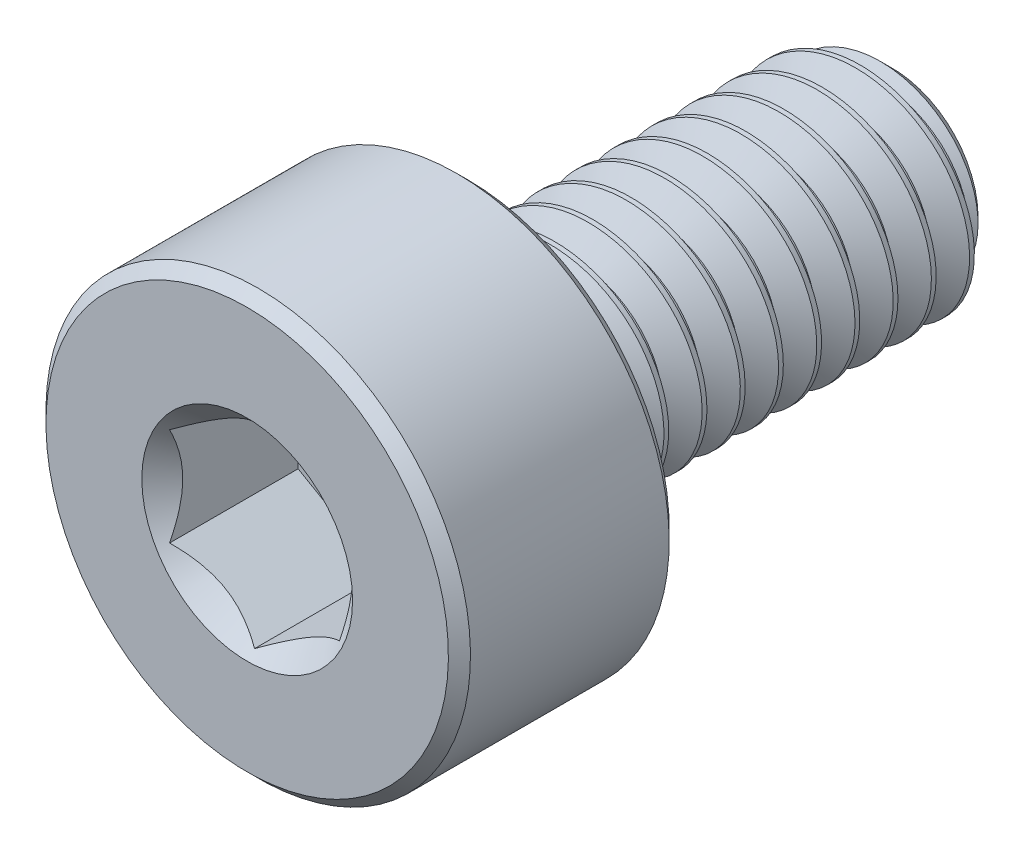
from build123d import *

# Parameters (mm, degrees)
CUT_EXTRUDE1_DEPTH     = 1.6
SPLIT1_SURFACE_1_BACK  = 11.381
SPLIT1_SURFACE_1_DEPTH = 22.762
SPLIT1_SURFACE_2_BACK  = 11.381
SPLIT1_SURFACE_2_DEPTH = 22.762
CUT_SWEEP1_PITCH       = 0.4500000000000005
CUT_SWEEP1_HEIGHT      = 5.45000000000001
CUT_SWEEP1_RADIUS      = 1.3
CUT_SWEEP1_START_ANGLE = 89.99999999999977


with BuildPart() as part:
    # Sketch2 → Revolve1 (revolve)
    with BuildSketch(Plane(origin=(0, 0, 0), x_dir=(0, 0, -1), z_dir=(1, 0, 0))):
        with BuildLine():
            Line((-3.799999999999998, 0), (-3.7999999999999994, 2.3699999999999997))
            Line((-3.7999999999999994, 2.3699999999999997), (-3.6699999999999995, 2.5))
            Line((-3.6699999999999995, 2.5), (-1.3299999999999996, 2.5))
            Line((-1.3299999999999996, 2.5), (-1.1999999999999997, 2.3699999999999997))
            Line((-1.1999999999999997, 2.3699999999999997), (-1.1999999999999997, 1.430000000000001))
            ThreePointArc((-1.1999999999999997, 1.430000000000001), (-1.1619238815542512, 1.3380761184457506), (-1.0700000000000007, 1.300000000000001))
            Line((-1.0700000000000007, 1.300000000000001), (3.507716426222749, 1.3))
            Line((3.507716426222749, 1.3), (3.7999999999999994, 1.0077164262227518))
            Line((3.7999999999999994, 1.0077164262227518), (3.799999999999998, 0))
            Line((3.799999999999998, 0), (-3.799999999999998, 0))
        make_face()
    revolve(axis=Axis((0, 0, -3.799999999999998), (0, 0, 1)))

    # Sketch3 → Cut-Extrude1 (cut)
    with BuildSketch(Plane.XY.offset(3.7999999999999985)):
        Polygon((1, -0.5773502691896257), (1, 0.5773502691896258), (-3.1e-16, 1.1547005383792517), (-1, 0.5773502691896255), (-1, -0.5773502691896258), (4.4e-16, -1.1547005383792517), align=None)
    extrude(amount=-CUT_EXTRUDE1_DEPTH, mode=Mode.SUBTRACT)

    # Cut-Extrude2 cone 1 section (through the dimple's axis) → Cut-Extrude2 (revolve, cut)
    with BuildSketch(Plane(origin=(0, 0, 3.8), x_dir=(0, -1, 0), z_dir=(1, 0, 0))):
        Polygon((0, 0), (1.241303079, 0), (0, 1.241303079), align=None)
    revolve(axis=Axis((0, 0, 3.8), (0, 0, -1)), mode=Mode.SUBTRACT)


with BuildPart() as body_2:
    # Split1: the piece behind the surface
    add(part.part)
    # Split1 surface: a surface, the sketch's curves swept straight by 22.762 mm
    with BuildLine(Plane(origin=(0, 0, 0), x_dir=(0, 0, -1), z_dir=(1, 0, 0)).offset(-SPLIT1_SURFACE_1_BACK), mode=Mode.PRIVATE) as split1_surface_1_path:
        Line((-1.0700000000000007, -2.5000000000000004), (-1.0700000000000007, 2.5000000000000004))
    split1_surface_1 = Shell.extrude(split1_surface_1_path.wire(), (1 * SPLIT1_SURFACE_1_DEPTH, 0 * SPLIT1_SURFACE_1_DEPTH, 0 * SPLIT1_SURFACE_1_DEPTH))
    split(bisect_by=split1_surface_1, keep=Keep.BOTTOM)

    # Cut-Sweep1: sweep along a helix
    with BuildLine() as cut_sweep1_path:
        add(Helix(CUT_SWEEP1_PITCH, CUT_SWEEP1_HEIGHT, CUT_SWEEP1_RADIUS, center=(0, 0, -3.7999999999999985), direction=(0, 0, 1), mode=Mode.PRIVATE).rotate(Axis((0, 0, -3.7999999999999985), (0, 0, 1)), CUT_SWEEP1_START_ANGLE))
    # Sketch7 → Cut-Sweep1 (sweep, cut)
    with BuildSketch(Plane(origin=(0, 0, 0), x_dir=(0, 0, -1), z_dir=(1, 0, 0))):
        Polygon((3.78593750000002, 1.324356964481437), (4.207812499999981, 1.324356964481437), (4.0249999999999995, 1.0077164262227518), (3.9687499999999982, 1.0077164262227518), align=None)
    sweep(path=cut_sweep1_path.line, is_frenet=True, mode=Mode.SUBTRACT)


with BuildPart() as part_1:
    add(part.part)

    # Split1: split by a surface, the side it looks to stays
    # Split1 surface: a surface, the sketch's curves swept straight by 22.762 mm
    with BuildLine(Plane(origin=(0, 0, 0), x_dir=(0, 0, -1), z_dir=(1, 0, 0)).offset(-SPLIT1_SURFACE_2_BACK), mode=Mode.PRIVATE) as split1_surface_2_path:
        Line((-1.0700000000000007, -2.5000000000000004), (-1.0700000000000007, 2.5000000000000004))
    split1_surface_2 = Shell.extrude(split1_surface_2_path.wire(), (1 * SPLIT1_SURFACE_2_DEPTH, 0 * SPLIT1_SURFACE_2_DEPTH, 0 * SPLIT1_SURFACE_2_DEPTH))
    split(bisect_by=split1_surface_2, keep=Keep.TOP)

    add(body_2.part)  # Revolve2 merges body 2
    # Sketch8 → Revolve2 (revolve)
    with BuildSketch(Plane(origin=(0, 0, 0), x_dir=(0, 0, -1), z_dir=(1, 0, 0)), mode=Mode.PRIVATE) as revolve2_sk:
        Polygon((-1.1999999999999997, -1e-17), (-1.1999999999999997, 1.3), (-1.0700000000000007, 1.3), (-0.3194446500534784, 1e-16), align=None)
    revolve(revolve2_sk.sketch.rotate(Axis((0, 1e-16, 0.3194446500534784), (0, -1.2e-16, 1)), 270), axis=Axis((0, 1e-16, 0.3194446500534784), (0, -1.2e-16, 1)))


solid = part_1.part
